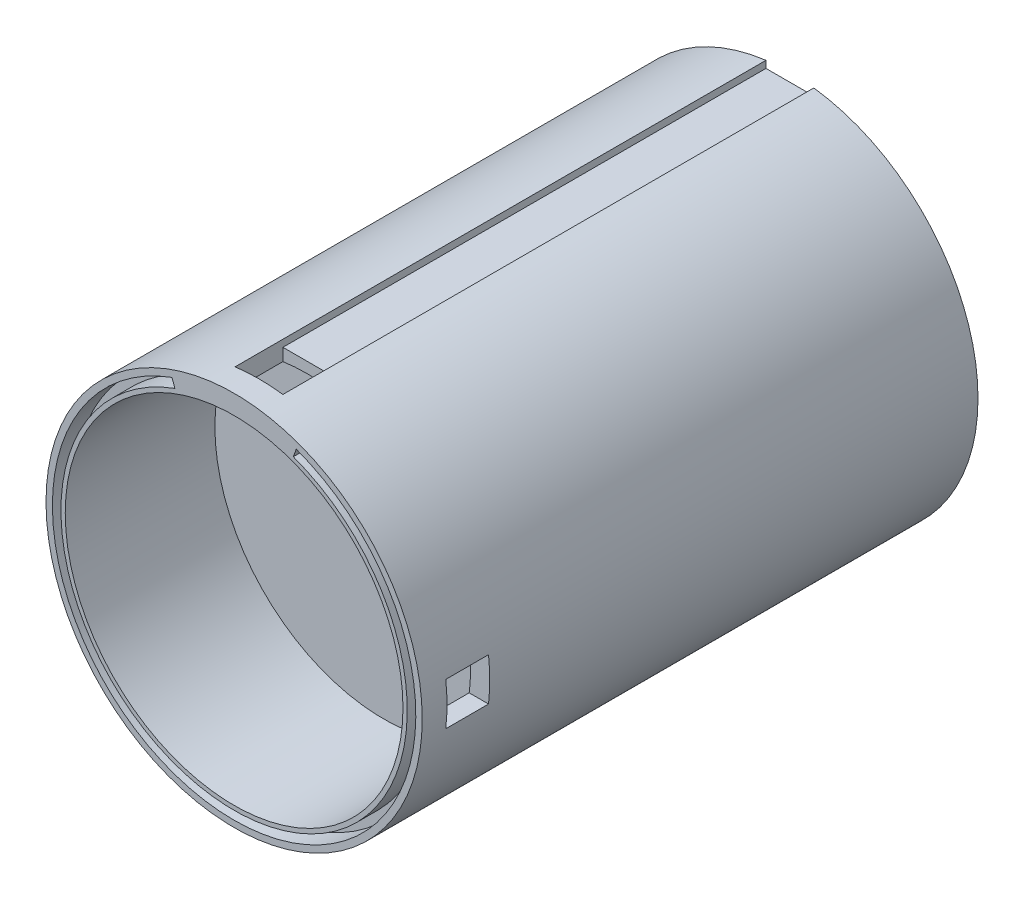
from build123d import *

# Parameters (mm, degrees)
SKETCH1_R               = 44
BOSS_EXTRUDE1_DEPTH     = 130
SKETCH2_R               = 39.5
CUT_EXTRUDE1_DEPTH      = 90
SKETCH3_R               = 39.5
CUT_EXTRUDE2_DEPTH      = 35
SKETCH6_W               = 11.193141888
SKETCH6_H               = 132.356748066
CUT_EXTRUDE3_DEPTH      = 95
SKETCH7_W               = 11.193141888
SKETCH7_H               = 11.193141887
CUT_EXTRUDE4_DEPTH      = 25
CUT_EXTRUDE5_DEPTH      = 5
SKETCH11_W              = 10
SKETCH11_H              = 10
CUT_EXTRUDE6_DEPTH      = 5
CUT_EXTRUDE6_DEPTH_BACK = 5


with BuildPart() as part:
    # Sketch1 → Boss-Extrude1 (new body)
    with BuildSketch(Plane.XY):
        Circle(SKETCH1_R)
    extrude(amount=BOSS_EXTRUDE1_DEPTH)

    # Sketch2 → Cut-Extrude1 (cut)
    with BuildSketch(Plane(origin=(0, 0, 0), x_dir=(-1, 0, 0), z_dir=(0, 0, -1))):
        Circle(SKETCH2_R)
    extrude(amount=-CUT_EXTRUDE1_DEPTH, mode=Mode.SUBTRACT)

    # Sketch3 → Cut-Extrude2 (cut)
    with BuildSketch(Plane.XY.offset(130)):
        Circle(SKETCH3_R)
    extrude(amount=-CUT_EXTRUDE2_DEPTH, mode=Mode.SUBTRACT)

    # Sketch6 → Cut-Extrude3 (cut)
    with BuildSketch(Plane(origin=(0, 42, 0), x_dir=(1, 0, 0), z_dir=(0, 1, 0))):
        with Locations((0, -58)):
            Rectangle(SKETCH6_W, SKETCH6_H)
    extrude(amount=CUT_EXTRUDE3_DEPTH, mode=Mode.SUBTRACT)

    # Sketch7 → Cut-Extrude4 (cut)
    with BuildSketch(Plane(origin=(0, 42, 0), x_dir=(1, 0, 0), z_dir=(0, 1, 0))):
        with Locations((0, -118.581803089)):
            Rectangle(SKETCH7_W, SKETCH7_H)
    extrude(amount=-CUT_EXTRUDE4_DEPTH, mode=Mode.SUBTRACT)

    # Sketch9 → Cut-Extrude5 (cut)
    with BuildSketch(Plane(origin=(0, 0, 0), x_dir=(-1, 0, 0), z_dir=(0, 0, -1))):
        with BuildLine():
            Line((14.535856091, 39.936936383), (13.851815805, 38.057551142))
            ThreePointArc((13.851815805, 38.057551142), (0, -40.5), (-13.851815805, 38.057551142))
            Line((-13.851815805, 38.057551142), (-14.535856091, 39.936936383))
            ThreePointArc((-14.535856091, 39.936936383), (0, -42.5), (14.535856091, 39.936936383))
        make_face()
    cut_extrude5 = extrude(amount=-CUT_EXTRUDE5_DEPTH, mode=Mode.SUBTRACT)

    # Sketch11 → Cut-Extrude6 (cut, two sides)
    with BuildSketch(Plane(origin=(40, 0, 0), x_dir=(0, 0, -1), z_dir=(1, 0, 0))) as cut_extrude6_sk:
        with Locations((-119.2, 0)):
            Rectangle(SKETCH11_W, SKETCH11_H)
    extrude(amount=CUT_EXTRUDE6_DEPTH, mode=Mode.SUBTRACT)
    extrude(cut_extrude6_sk.sketch, amount=-CUT_EXTRUDE6_DEPTH_BACK, mode=Mode.SUBTRACT)

    # Mirror1: Cut-Extrude5 across plane
    add(cut_extrude5.mirror(Plane(origin=(0, 0, 65), x_dir=(1, 0, 0), z_dir=(0, 0, -1))), mode=Mode.SUBTRACT)


solid = part.part
